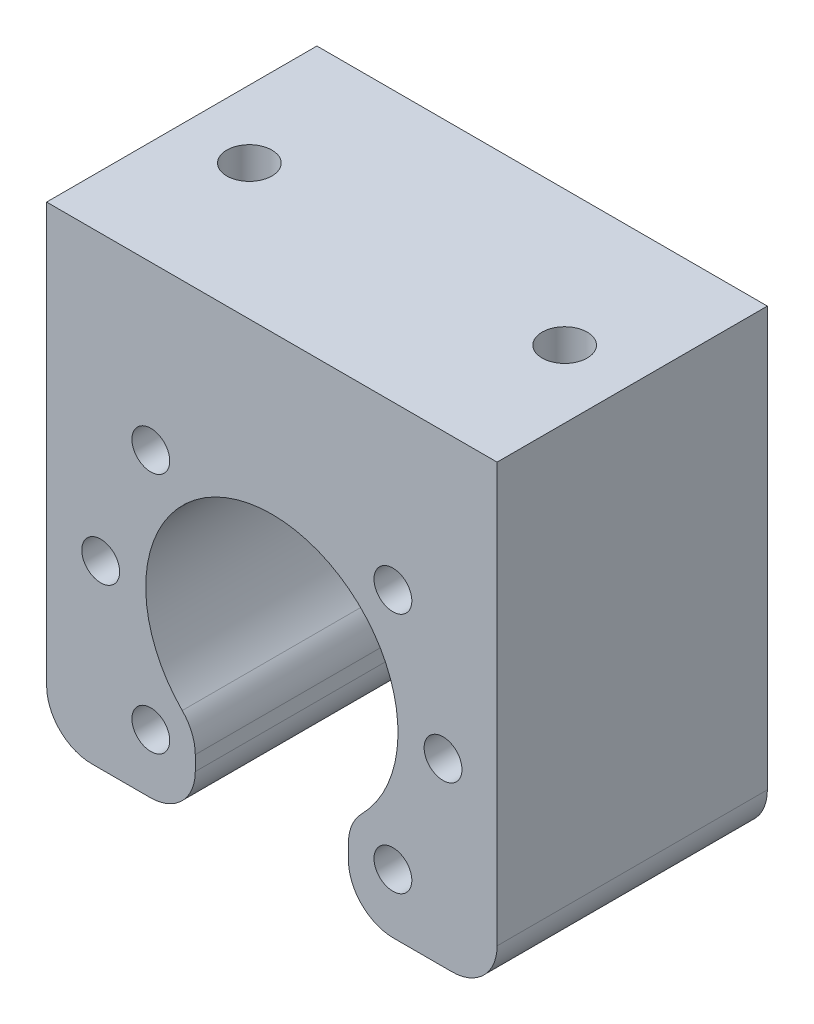
from build123d import *

# Parameters (mm, degrees)
EXTRUDE1_DEPTH        = 30
FILLET1_R             = 5
M5_TAPPED_HOLE1_D     = 4.2
M6_TAPPED_HOLE1_D     = 5
M6_TAPPED_HOLE1_DEPTH = 20
M6_TAPPED_HOLE1_TIP   = 1.502151548


with BuildPart() as part:
    # Sketch1 → Extrude1 (new body)
    with BuildSketch(Plane.XY):
        with BuildLine():
            Line((-25, 31.5), (25, 31.5))
            Line((25, 31.5), (25, -20))
            Line((25, -20), (8.5, -20))
            Line((8.5, -20), (8.5, -11.124297731))
            ThreePointArc((8.5, -11.124297731), (0, 14), (-8.5, -11.124297731))
            Line((-8.5, -11.124297731), (-8.5, -20))
            Line((-8.5, -20), (-25, -20))
            Line((-25, -20), (-25, 31.5))
        make_face()
    extrude(amount=EXTRUDE1_DEPTH)

    # Fillet1
    fillet1_edges = [part.edges().sort_by_distance(p)[0] for p in [
        (-8.5, -20, 15),
        (-25, -20, 15),
        (25, -20, 15),
        (8.5, -20, 15),
        (8.5, -11.124297731, 15),
        (-8.5, -11.124297731, 15),
    ]]
    fillet(fillet1_edges, radius=FILLET1_R)

    # M5 Tapped Hole1 (through all)
    with Locations(Plane(origin=(0, 0, 0), x_dir=(-1, 0, 0), z_dir=(0, 0, -1))):
        with Locations((-13.435028843, 13.435028843), (13.435028843, 13.435028843), (19, 0), (13.435028843, -13.435028843), (-13.435028843, -13.435028843), (-19, 0)):
            Hole(M5_TAPPED_HOLE1_D / 2)

    # M6 Tapped Hole1
    with Locations(Plane(origin=(0, 31.5, 0), x_dir=(1, 0, 0), z_dir=(0, 1, 0))):
        with Locations((-17.5, -15), (17.5, -15)):
            Hole(M6_TAPPED_HOLE1_D / 2, depth=M6_TAPPED_HOLE1_DEPTH)
            with Locations((0, 0, -(M6_TAPPED_HOLE1_DEPTH + M6_TAPPED_HOLE1_TIP / 2))):  # 118° drill point
                Cone(0, M6_TAPPED_HOLE1_D / 2, M6_TAPPED_HOLE1_TIP, mode=Mode.SUBTRACT)


solid = part.part
